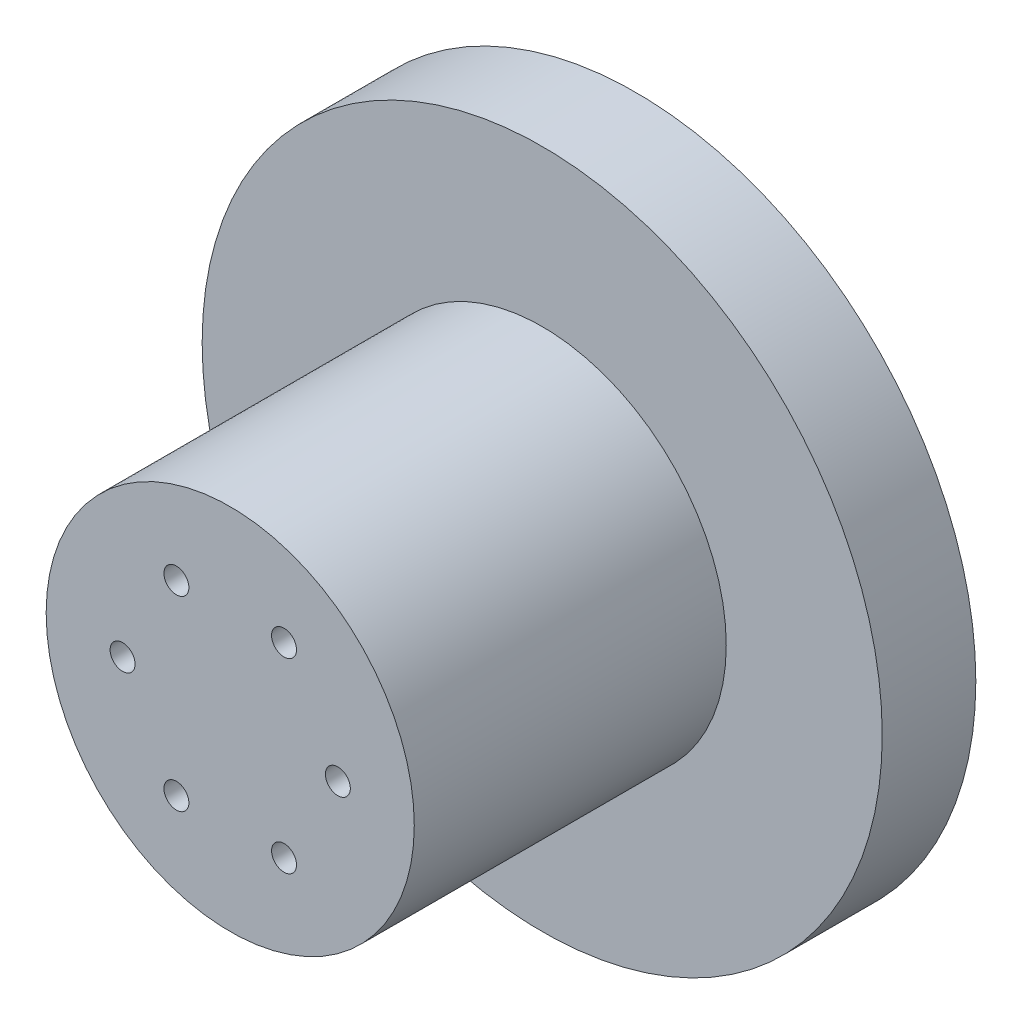
from build123d import *

# Parameters (mm, degrees)
SKETCH_1_R          = 29.5
EXTRUDE_1_DEPTH     = 50
SHELL_2_T           = -4
SKETCH_3_R          = 2
CUT_EXTRUDE_1_DEPTH = 66.119121616
SKETCH_5_R          = 54.5
SKETCH_5_R_2        = 29.5
SKETCH_5_R_3        = 25.5
EXTRUDE_7_DEPTH     = 15
SKETCH_6_R          = 2
CUT_EXTRUDE_3_DEPTH = 4


with BuildPart() as part:
    # 草图1 → 凸台-拉伸1 (new body)
    with BuildSketch(Plane.XY):
        Circle(SKETCH_1_R)
    extrude(amount=EXTRUDE_1_DEPTH)

    # 抽壳2
    shell_2_openings = [part.faces().sort_by_distance(p)[0] for p in [
        (0, 0, 0),
    ]]
    offset(amount=SHELL_2_T, openings=shell_2_openings, kind=Kind.INTERSECTION)

    # 草图3 → 切除-拉伸1 (cut, through all)
    with BuildSketch(Plane.XY.offset(50)):
        with Locations((-17.25, 0)):
            Circle(SKETCH_3_R)
        with Locations((-8.625, 14.938938215)):
            Circle(SKETCH_3_R)
        with Locations((8.625, 14.938938215)):
            Circle(SKETCH_3_R)
        with Locations((17.25, 0)):
            Circle(SKETCH_3_R)
        with Locations((8.625, -14.938938215)):
            Circle(SKETCH_3_R)
        with Locations((-8.625, -14.938938215)):
            Circle(SKETCH_3_R)
    extrude(amount=-CUT_EXTRUDE_1_DEPTH, mode=Mode.SUBTRACT)

    # 草图5 → 凸台-拉伸7 (add)
    with BuildSketch(Plane(origin=(0, 0, 0), x_dir=(-1, 0, 0), z_dir=(0, 0, -1))):
        Circle(SKETCH_5_R)
        with Locations(Location((0, 0, 0), (0, 0, 180))):
            Circle(SKETCH_5_R_2, mode=Mode.SUBTRACT)
        with Locations(Location((0, 0, 0), (0, 0, 180))):
            Circle(SKETCH_5_R_2)
        Circle(SKETCH_5_R_3, mode=Mode.SUBTRACT)
    extrude(amount=EXTRUDE_7_DEPTH)

    # 草图6 → 切除-拉伸3 (cut)
    with BuildSketch(Plane(origin=(0, 0, -15), x_dir=(-1, 0, 0), z_dir=(0, 0, -1))):
        with Locations((-42, 0)):
            Circle(SKETCH_6_R)
        with Locations((42, 0)):
            Circle(SKETCH_6_R)
    extrude(amount=-CUT_EXTRUDE_3_DEPTH, mode=Mode.SUBTRACT)


solid = part.part
